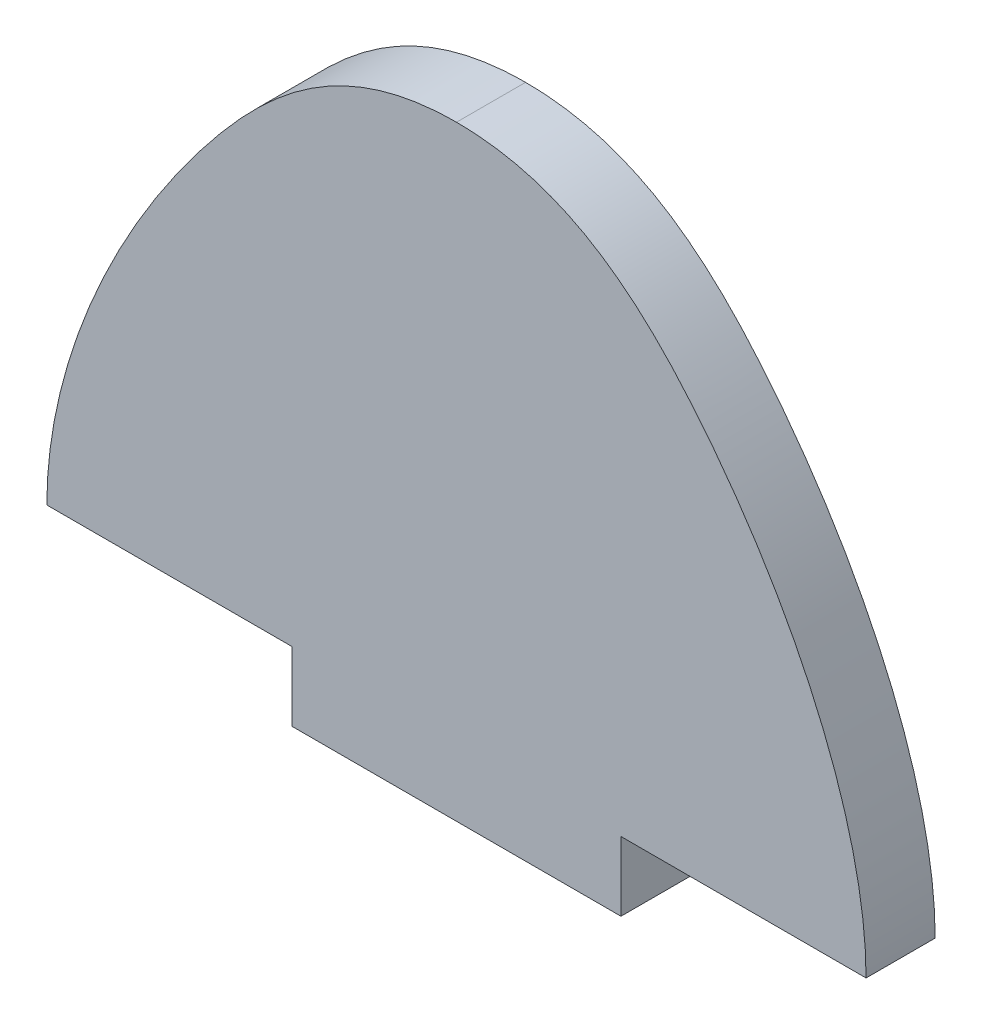
from build123d import *

# Parameters (mm, degrees)
SKETCH1_W           = 25.4
SKETCH1_H           = 5.334
BOSS_EXTRUDE1_DEPTH = 5.334


with BuildPart() as part:
    # Sketch1 → Boss-Extrude1 (new body)
    with BuildSketch(Plane.XY):
        with BuildLine():
            Line((52.578, 0), (35.814, 0))
            Line((35.814, 0), (16.764, 0))
            Line((16.764, 0), (0, 0))
            Line((0, 0), (-5.334, 0))
            add(Edge.make_bspline(
                [(-5.334, 0), (-5.334, 10.018830831), (3.631454695, 29.285599761), (17.689605538, 41.402), (26.289, 41.402)],
                knots=[0, 0, 0, 0, 0.604390218, 1, 1, 1, 1], degree=3))
            add(Edge.make_bspline(
                [(57.912, 0), (57.912, 10.018830831), (48.946545305, 29.285599761), (34.888394462, 41.402), (26.289, 41.402)],
                knots=[0, 0, 0, 0, 0.604390218, 1, 1, 1, 1], degree=3))
            Line((57.912, 0), (52.578, 0))
        make_face()
        with Locations((26.289, -2.667)):
            Rectangle(SKETCH1_W, SKETCH1_H)
    extrude(amount=BOSS_EXTRUDE1_DEPTH)


solid = part.part
